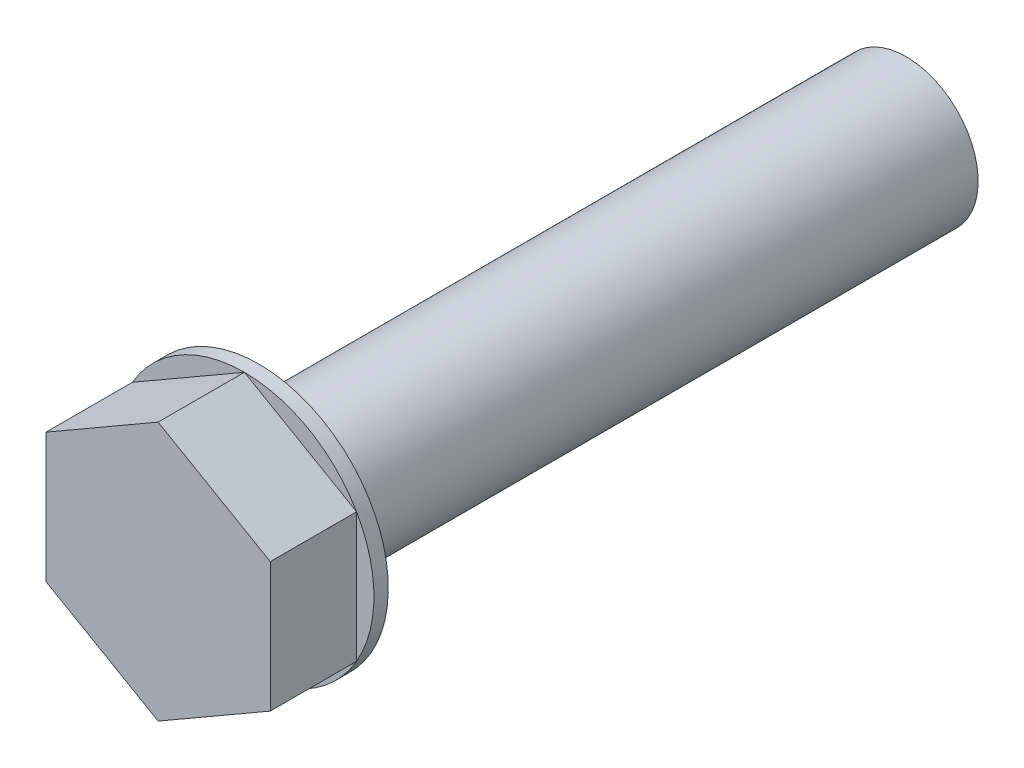
from build123d import *

# Parameters (mm, degrees)
BOSS_EXTRUDE1_DEPTH = 6
SKETCH2_R           = 9
BOSS_EXTRUDE2_DEPTH = 1
SKETCH3_R           = 5
BOSS_EXTRUDE3_DEPTH = 45


with BuildPart() as part:
    # Sketch1 → Boss-Extrude1 (new body)
    with BuildSketch(Plane.XY):
        Polygon((0, 9), (-7.794228634, 4.5), (-7.794228634, -4.5), (0, -9), (7.794228634, -4.5), (7.794228634, 4.5), align=None)
    extrude(amount=BOSS_EXTRUDE1_DEPTH)

    # Sketch2 → Boss-Extrude2 (add)
    with BuildSketch(Plane(origin=(0, 0, 0), x_dir=(-1, 0, 0), z_dir=(0, 0, -1))):
        Circle(SKETCH2_R)
    extrude(amount=BOSS_EXTRUDE2_DEPTH)

    # Sketch3 → Boss-Extrude3 (add)
    with BuildSketch(Plane(origin=(0, 0, -1), x_dir=(-1, 0, 0), z_dir=(0, 0, -1))):
        Circle(SKETCH3_R)
    extrude(amount=BOSS_EXTRUDE3_DEPTH)


solid = part.part
